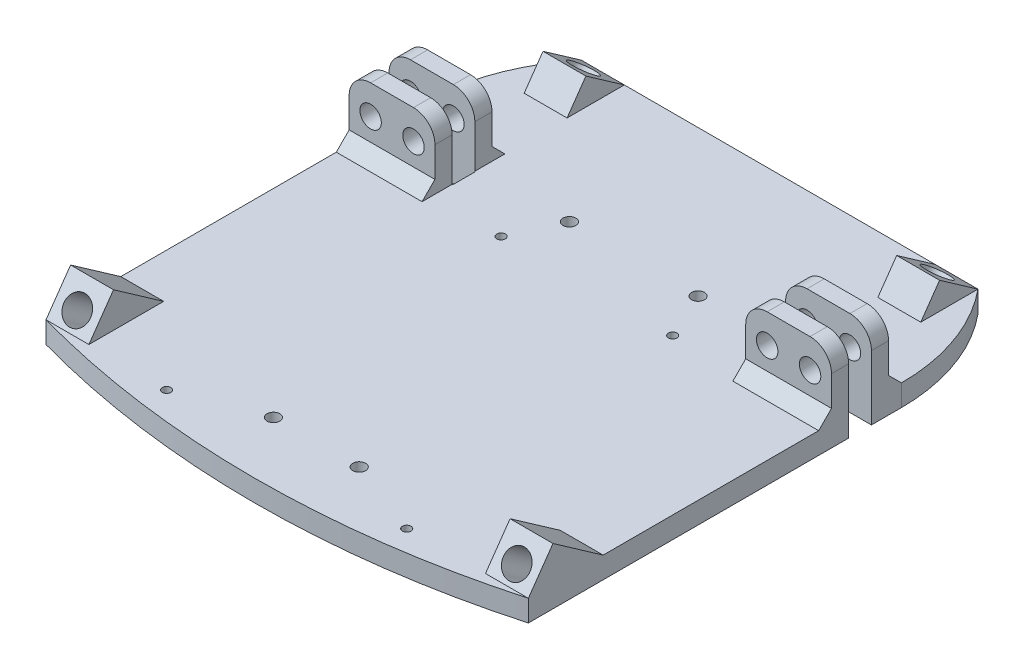
from build123d import *

# Parameters (mm, degrees)
BOSS_EXTRUDE1_DEPTH      = 2.5
BOSS_EXTRUDE2_DEPTH      = 10
SKETCH3_R                = 3.1
CUT_EXTRUDE1_DEPTH       = 97.926231277
BOSS_EXTRUDE3_DEPTH      = 10
SKETCH5_R                = 3.1
CUT_EXTRUDE2_DEPTH       = 73.924932584
SKETCH6_W                = 5.175957564
SKETCH6_H                = 5
CUT_EXTRUDE3_DEPTH       = 113.454585159
SKETCH7_W                = 20.15
SKETCH7_H                = 0.476848187
BOSS_EXTRUDE4_DEPTH      = 5
SKETCH7_3_W              = 20.15
SKETCH7_3_H              = 0.476848187
CUT_EXTRUDE4_DEPTH       = 5
SKETCH8_W                = 4
SKETCH8_H                = 15
BOSS_EXTRUDE5_DEPTH      = 20
SKETCH9_R                = 2.5
CUT_EXTRUDE5_DEPTH       = 13.3
FILLET1_R                = 5
CHAMFER1_SIZE            = 3
FILLET1_OF_MIRROR2_R     = 5
CHAMFER1_OF_MIRROR2_SIZE = 3
BOSS_EXTRUDE6_DEPTH      = 5
SKETCH11_R               = 1
CUT_EXTRUDE6_DEPTH       = 6
SKETCH12_R               = 1.5
CUT_EXTRUDE7_DEPTH       = 21
CUT_EXTRUDE8_DEPTH       = 6


with BuildPart() as part:
    # Sketch1 → Boss-Extrude1 (new body, symmetric)
    with BuildSketch(Plane(origin=(-32.81203924, 33.9517387, -54.90733973), x_dir=(-1, 0, 0), z_dir=(0, -1, 0))):
        Polygon((57.454585159, 35), (-55, 35), (-55, 0.15), (-34.85, 0.15), (-34.85, -5.15), (-55, -5.15), (-55, -85), (57.454585159, -85), (57.454585159, -4.673151813), (37.304585159, -4.673151813), (37.304585159, 0.626848187), (57.454585159, 0.626848187), align=None)
    extrude(amount=BOSS_EXTRUDE1_DEPTH, both=True)

    # Sketch2 → Boss-Extrude2 (add)
    with BuildSketch(Plane.ZY.offset(90.266624399)):
        Polygon((7.48223475, 36.4517387), (19.180938343, 44.643259143), (24.916702706, 36.4517387), align=None)
    boss_extrude2 = extrude(amount=-BOSS_EXTRUDE2_DEPTH)

    # Sketch3 → Cut-Extrude1 (cut, through all)
    with BuildSketch(Plane(origin=(0, 23.699275736, 33.846073404), x_dir=(1, 0, 0), z_dir=(0, 0.573576436, 0.819152044))):
        with Locations((-85.266624399, 19.56788273)):
            Circle(SKETCH3_R)
    cut_extrude1 = extrude(amount=-CUT_EXTRUDE1_DEPTH, mode=Mode.SUBTRACT)

    # Sketch4 → Boss-Extrude3 (add)
    with BuildSketch(Plane(origin=(-70.266624399, 0, 0), x_dir=(0, 0, -1), z_dir=(1, 0, 0))):
        Polygon((76.559676692, 36.4517387), (80.950923398, 42.723088931), (89.90733973, 36.4517387), align=None)
    boss_extrude3 = extrude(amount=-BOSS_EXTRUDE3_DEPTH)

    # Sketch5 → Cut-Extrude2 (cut, through all)
    with BuildSketch(Plane(origin=(0, 66.702115647, -46.70532419), x_dir=(1, 0, 0), z_dir=(0, 0.819152044, -0.573576436))):
        with Locations((-75.266624399, 47.224033141)):
            Circle(SKETCH5_R)
    cut_extrude2 = extrude(amount=-CUT_EXTRUDE2_DEPTH, mode=Mode.SUBTRACT)

    # Mirror1: Boss-Extrude2, Cut-Extrude1, Boss-Extrude3, Cut-Extrude2 across plane
    add(boss_extrude2.mirror(Plane.ZY.offset(34.03933182)))
    add(cut_extrude1.mirror(Plane.ZY.offset(34.03933182)), mode=Mode.SUBTRACT)
    add(boss_extrude3.mirror(Plane.ZY.offset(34.03933182)))
    add(cut_extrude2.mirror(Plane.ZY.offset(34.03933182)), mode=Mode.SUBTRACT)

    # Sketch6 → Cut-Extrude3 (cut, through all)
    with BuildSketch(Plane.ZY.offset(90.266624399)):
        with Locations((27.504681488, 33.9517387)):
            Rectangle(SKETCH6_W, SKETCH6_H)
    extrude(amount=-CUT_EXTRUDE3_DEPTH, mode=Mode.SUBTRACT)

    # Sketch7 → Boss-Extrude4 (add)
    with BuildSketch(Plane(origin=(0, 36.4517387, 0), x_dir=(1, 0, 0), z_dir=(0, 1, 0))):
        with Locations((-80.191624399, 55.295763824)):
            Rectangle(SKETCH7_W, SKETCH7_H)
    boss_extrude4 = extrude(amount=-BOSS_EXTRUDE4_DEPTH)

    # Sketch7_3 → Cut-Extrude4 (cut)
    with BuildSketch(Plane(origin=(0, 36.4517387, 0), x_dir=(1, 0, 0), z_dir=(0, 1, 0))):
        with Locations((-80.191624399, 49.995763823)):
            Rectangle(SKETCH7_3_W, SKETCH7_3_H)
    cut_extrude4 = extrude(amount=-CUT_EXTRUDE4_DEPTH, mode=Mode.SUBTRACT)

    # Sketch8 → Boss-Extrude5 (add)
    with BuildSketch(Plane.ZY.offset(90.266624399)):
        with Locations((-57.05733973, 43.9517387)):
            Rectangle(SKETCH8_W, SKETCH8_H)
        with Locations((-47.75733973, 43.9517387)):
            Rectangle(SKETCH8_W, SKETCH8_H)
    boss_extrude5 = extrude(amount=-BOSS_EXTRUDE5_DEPTH)

    # Sketch9 → Cut-Extrude5 (cut)
    with BuildSketch(Plane(origin=(0, 0, -59.05733973), x_dir=(-1, 0, 0), z_dir=(0, 0, -1))):
        with Locations((75.266624399, 44.643259143)):
            Circle(SKETCH9_R)
        with Locations((85.266624399, 44.643259143)):
            Circle(SKETCH9_R)
    cut_extrude5 = extrude(amount=-CUT_EXTRUDE5_DEPTH, mode=Mode.SUBTRACT)

    # Fillet1
    fillet1_edges = [part.edges().sort_by_distance(p)[0] for p in [
        (-70.266624399, 51.4517387, -57.05733973),
        (-90.266624399, 51.4517387, -57.05733973),
        (-70.266624399, 51.4517387, -47.75733973),
        (-90.266624399, 51.4517387, -47.75733973),
    ]]
    fillet(fillet1_edges, radius=FILLET1_R)

    # Chamfer1
    chamfer1_edges = [part.edges().sort_by_distance(p)[0] for p in [
        (-80.266624399, 36.4517387, -59.05733973),
        (-80.266624399, 36.4517387, -45.75733973),
    ]]
    chamfer(chamfer1_edges, length=CHAMFER1_SIZE)

    # Mirror2: Boss-Extrude4, Cut-Extrude4, Boss-Extrude5, Cut-Extrude5 across plane
    add(boss_extrude4.mirror(Plane.ZY.offset(34.03933182)))
    add(cut_extrude4.mirror(Plane.ZY.offset(34.03933182)), mode=Mode.SUBTRACT)
    add(boss_extrude5.mirror(Plane.ZY.offset(34.03933182)))
    add(cut_extrude5.mirror(Plane.ZY.offset(34.03933182)), mode=Mode.SUBTRACT)

    # Fillet1 of Mirror2
    fillet1_of_mirror2_edges = [part.edges().sort_by_distance(p)[0] for p in [
        (2.18796076, 51.4517387, -57.05733973),
        (22.18796076, 51.4517387, -57.05733973),
        (2.18796076, 51.4517387, -47.75733973),
        (22.18796076, 51.4517387, -47.75733973),
    ]]
    fillet(fillet1_of_mirror2_edges, radius=FILLET1_OF_MIRROR2_R)

    # Chamfer1 of Mirror2
    chamfer1_of_mirror2_edges = [part.edges().sort_by_distance(p)[0] for p in [
        (12.18796076, 36.4517387, -59.05733973),
        (12.18796076, 36.4517387, -45.75733973),
    ]]
    chamfer(chamfer1_of_mirror2_edges, length=CHAMFER1_OF_MIRROR2_SIZE)

    # Sketch10 → Boss-Extrude6 (add)
    with BuildSketch(Plane(origin=(0, 36.4517387, 0), x_dir=(1, 0, 0), z_dir=(0, 1, 0))):
        with BuildLine():
            Line((-90.266624399, -24.916702706), (22.18796076, -24.916702706))
            ThreePointArc((22.18796076, -24.916702706), (-34.03933182, -32.584076644), (-90.266624399, -24.916702706))
        make_face()
    extrude(amount=-BOSS_EXTRUDE6_DEPTH)

    # Sketch11 → Cut-Extrude6 (cut, through all)
    with BuildSketch(Plane(origin=(0, 36.4517387, 0), x_dir=(1, 0, 0), z_dir=(0, 1, 0))):
        with Locations((-54.03933182, 44.951248934)):
            Circle(SKETCH11_R)
        with Locations((-14.03933182, 44.951248934)):
            Circle(SKETCH11_R)
        with Locations((-6.03933182, -25.048751066)):
            Circle(SKETCH11_R)
        with Locations((-62.03933182, -25.048751066)):
            Circle(SKETCH11_R)
    extrude(amount=-CUT_EXTRUDE6_DEPTH, mode=Mode.SUBTRACT)

    # Sketch12 → Cut-Extrude7 (cut, through all)
    with BuildSketch(Plane.XZ.offset(-31.4517387)):
        with Locations((-19.03933182, -55.87359945)):
            Circle(SKETCH12_R)
        with Locations((-24.03933182, 18.12640055)):
            Circle(SKETCH12_R)
        with Locations((-49.03933182, -55.87359945)):
            Circle(SKETCH12_R)
        with Locations((-44.03933182, 18.12640055)):
            Circle(SKETCH12_R)
    extrude(amount=-CUT_EXTRUDE7_DEPTH, mode=Mode.SUBTRACT)

    # Sketch13 → Cut-Extrude8 (cut, through all)
    with BuildSketch(Plane(origin=(0, 36.4517387, 0), x_dir=(1, 0, 0), z_dir=(0, 1, 0))):
        with BuildLine():
            ThreePointArc((-90.266624399, 62.05733973), (-87.690854406, 76.852799337), (-80.266624399, 89.90733973))
            Line((-80.266624399, 89.90733973), (-90.266624399, 89.90733973))
            Line((-90.266624399, 89.90733973), (-90.266624399, 62.05733973))
        make_face()
        with BuildLine():
            ThreePointArc((22.18796076, 62.05733973), (19.612190767, 76.852799337), (12.18796076, 89.90733973))
            Line((12.18796076, 89.90733973), (22.18796076, 89.90733973))
            Line((22.18796076, 89.90733973), (22.18796076, 62.05733973))
        make_face()
    extrude(amount=-CUT_EXTRUDE8_DEPTH, mode=Mode.SUBTRACT)


solid = part.part
